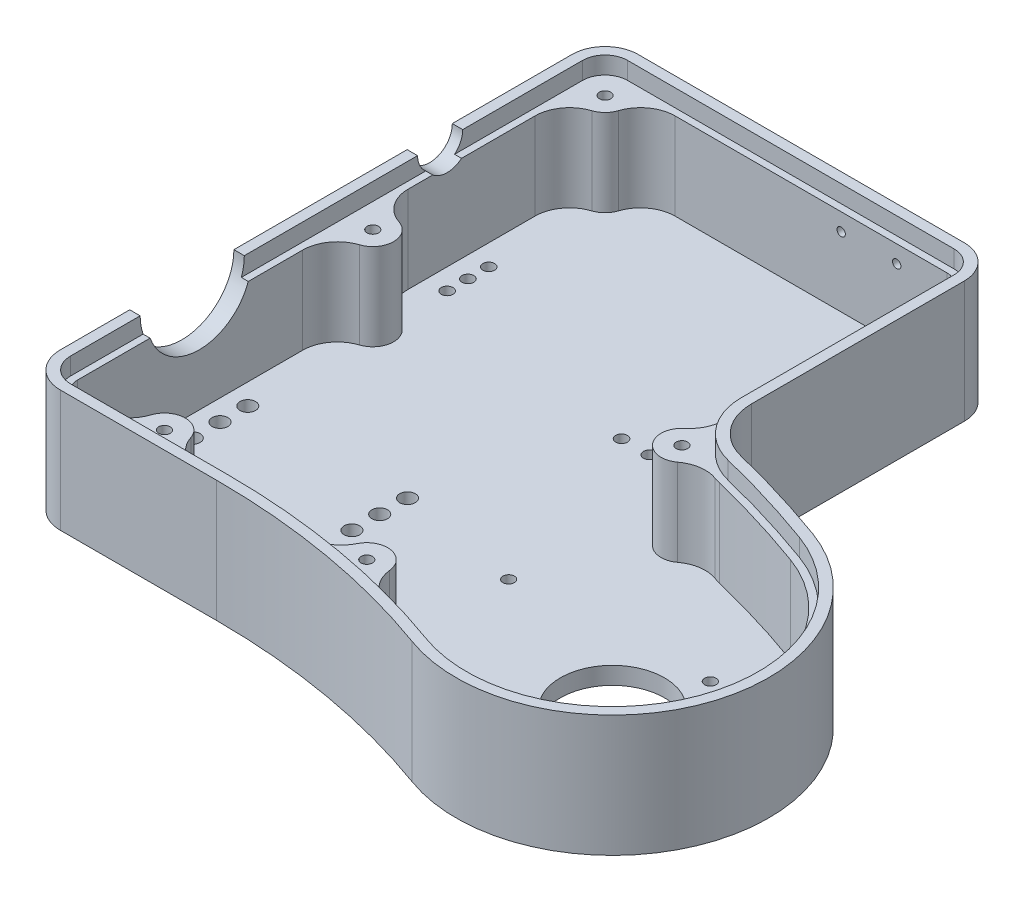
from build123d import *

# Parameters (mm, degrees)
EXTRUDE_1_DEPTH                  = 35
CUT_EXTRUDE_1_DEPTH              = 30
SKETCH_4_R                       = 15
CUT_EXTRUDE_3_DEPTH              = 10
SKETCH_9_R                       = 6.5
CUT_EXTRUDE_6_DEPTH              = 5
CUT_EXTRUDE_8_REACH              = 183.675
SKETCH_12_R                      = 1.2
CUT_EXTRUDE_9_DEPTH              = 5
CUT_EXTRUDE_10_REACH             = 7
SKETCH_14_R                      = 1.7
SKETCH_15_R                      = 1.7
CUT_EXTRUDE_11_DEPTH             = 5
SKETCH_21_R                      = 6
EXTRUDE_7_DEPTH                  = 25
FILLET_1_R                       = 10
FILLET_2_R                       = 10
FILLET_3_R                       = 10
CUT_EXTRUDE_17_REACH             = 7
SKETCH_23_R                      = 2.25
SKETCH_24_R                      = 2.25
CUT_EXTRUDE_18_DEPTH             = 36
HOLE_WIZARD_M4_1_D               = 3.3
HOLE_WIZARD_M4_1_DEPTH           = 11.5
HOLE_WIZARD_M4_1_TIP             = 0.991420021
CUT_EXTRUDE_19_REACH             = 37
SKETCH_3_R                       = 15
CUT_EXTRUDE_19_DIRECTION_2_DEPTH = 1
HOLE_WIZARD_M4_2_D               = 3.3
HOLE_WIZARD_M4_2_DEPTH           = 11.5
HOLE_WIZARD_M4_2_TIP             = 0.991420021


with BuildPart() as part:
    # 스케치1 → 보스-돌출1 (new body)
    with BuildSketch(Plane(origin=(0, 0, 0), x_dir=(1, 0, 0), z_dir=(0, 1, 0))):
        with BuildLine():
            Line((-35.5, 121.9), (10, 121.9))
            Line((10, 121.9), (58.5, 121.9))
            ThreePointArc((58.5, 121.9), (65.217514421, 119.117514421), (68, 112.4))
            Line((68, 112.4), (68, 51.135104302))
            ThreePointArc((68, 51.135104302), (71.192111556, 41.884495106), (79.409836066, 36.571082779))
            ThreePointArc((79.409836066, 36.571082779), (94.419473689, 32.440718825), (109.185841564, 27.510860028))
            ThreePointArc((109.185841564, 27.510860028), (136.08110305, -30.166214357), (78.404028665, -57.061475843))
            ThreePointArc((78.404028665, -57.061475843), (44.729635533, -48.038449398), (10, -45))
            Line((10, -45), (-35, -45))
            ThreePointArc((-35, -45), (-42.071067812, -42.071067812), (-45, -35))
            Line((-45, -35), (-45, 112.4))
            ThreePointArc((-45, 112.4), (-42.217514421, 119.117514421), (-35.5, 121.9))
        make_face()
    extrude(amount=EXTRUDE_1_DEPTH)

    # 스케치2 → 컷-돌출1 (cut)
    with BuildSketch(Plane(origin=(0, 35, 0), x_dir=(1, 0, 0), z_dir=(0, 1, 0))):
        with BuildLine():
            Line((-40, 112.4), (-40, -35))
            ThreePointArc((-40, -35), (-38.535533906, -38.535533906), (-35, -40))
            Line((-35, -40), (10, -40))
            ThreePointArc((10, -40), (45.597876422, -43.114410632), (80.114129382, -52.363012739))
            ThreePointArc((80.114129382, -52.363012739), (131.382639946, -28.45611364), (107.475740848, 22.812396924))
            ThreePointArc((107.475740848, 22.812396924), (92.963965522, 27.657258155), (78.213114754, 31.716408938))
            ThreePointArc((78.213114754, 31.716408938), (67.256148741, 38.800958708), (63, 51.135104302))
            Line((63, 51.135104302), (63, 112.4))
            ThreePointArc((63, 112.4), (61.681980515, 115.581980515), (58.5, 116.9))
            Line((58.5, 116.9), (-35.5, 116.9))
            ThreePointArc((-35.5, 116.9), (-38.681980515, 115.581980515), (-40, 112.4))
        make_face()
    extrude(amount=-CUT_EXTRUDE_1_DEPTH, mode=Mode.SUBTRACT)

    # 스케치4 → 컷-돌출3 (cut)
    with BuildSketch(Plane.ZY.offset(45)):
        with Locations((0, 35)):
            Circle(SKETCH_4_R)
    extrude(amount=-CUT_EXTRUDE_3_DEPTH, mode=Mode.SUBTRACT)

    # 스케치9 → 컷-돌출6 (cut)
    with BuildSketch(Plane.ZY.offset(45)):
        with Locations((-71.4, 35)):
            Circle(SKETCH_9_R)
    extrude(amount=-CUT_EXTRUDE_6_DEPTH, mode=Mode.SUBTRACT)

    # 스케치12 → 컷-돌출8 (cut, up to next)
    with BuildSketch(Plane(origin=(0, 0, -121.9), x_dir=(-1, 0, 0), z_dir=(0, 0, -1)), mode=Mode.PRIVATE) as cut_extrude_8_sk1:
        with Locations((-44, 25)):
            Circle(SKETCH_12_R)
    cut_extrude_8_tool1 = extrude(cut_extrude_8_sk1.sketch, amount=-CUT_EXTRUDE_8_REACH, mode=Mode.PRIVATE) & part.part
    add(cut_extrude_8_tool1.solids().sort_by_distance((44, 25, -121.9))[0], mode=Mode.SUBTRACT)
    # 스케치12 → 컷-돌출8 (cut, up to next)
    with BuildSketch(Plane(origin=(0, 0, -121.9), x_dir=(-1, 0, 0), z_dir=(0, 0, -1)), mode=Mode.PRIVATE) as cut_extrude_8_sk2:
        with Locations((-28, 25)):
            Circle(SKETCH_12_R)
    cut_extrude_8_tool2 = extrude(cut_extrude_8_sk2.sketch, amount=-CUT_EXTRUDE_8_REACH, mode=Mode.PRIVATE) & part.part
    add(cut_extrude_8_tool2.solids().sort_by_distance((28, 25, -121.9))[0], mode=Mode.SUBTRACT)

    # 스케치13 → 컷-돌출9 (cut)
    with BuildSketch(Plane(origin=(0, 35, 0), x_dir=(1, 0, 0), z_dir=(0, 1, 0))):
        with BuildLine():
            Line((-42, -35), (-42, -28.086909805))
            Line((-42, -28.086909805), (-42, 64.9))
            Line((-42, 64.9), (-42, 77.9))
            Line((-42, 77.9), (-42, 112.4))
            ThreePointArc((-42, 112.4), (-40.096194078, 116.996194078), (-35.5, 118.9))
            Line((-35.5, 118.9), (58.5, 118.9))
            ThreePointArc((58.5, 118.9), (63.096194078, 116.996194078), (65, 112.4))
            Line((65, 112.4), (65, 51.135104302))
            ThreePointArc((65, 51.135104302), (68.830533867, 40.034373267), (78.691803279, 33.658278474))
            ThreePointArc((78.691803279, 33.658278474), (93.546168789, 29.570642423), (108.159781134, 24.691782166))
            ThreePointArc((108.159781134, 24.691782166), (133.262025188, -29.140153927), (79.430089095, -54.24239798))
            ThreePointArc((79.430089095, -54.24239798), (45.250580066, -45.084026139), (10, -42))
            Line((10, -42), (-35, -42))
            ThreePointArc((-35, -42), (-39.949747468, -39.949747468), (-42, -35))
        make_face()
        with BuildLine():
            Line((-40, -28.086909805), (-40, -35))
            ThreePointArc((-40, -35), (-38.535533906, -38.535533906), (-35, -40))
            Line((-35, -40), (10, -40))
            ThreePointArc((10, -40), (45.597876422, -43.114410632), (80.114129382, -52.363012739))
            ThreePointArc((80.114129382, -52.363012739), (131.382639946, -28.45611364), (107.475740848, 22.812396924))
            ThreePointArc((107.475740848, 22.812396924), (92.963965522, 27.657258155), (78.213114754, 31.716408938))
            ThreePointArc((78.213114754, 31.716408938), (67.256148741, 38.800958708), (63, 51.135104302))
            Line((63, 51.135104302), (63, 112.4))
            ThreePointArc((63, 112.4), (61.681980515, 115.581980515), (58.5, 116.9))
            Line((58.5, 116.9), (-35.5, 116.9))
            ThreePointArc((-35.5, 116.9), (-38.681980515, 115.581980515), (-40, 112.4))
            Line((-40, 112.4), (-40, 77.9))
            Line((-40, 77.9), (-40, 64.9))
            Line((-40, 64.9), (-40, -28.086909805))
        make_face(mode=Mode.SUBTRACT)
    extrude(amount=-CUT_EXTRUDE_9_DEPTH, mode=Mode.SUBTRACT)

    # 스케치14 → 컷-돌출10 (cut, up to next)
    with BuildSketch(Plane(origin=(0, 5, 0), x_dir=(1, 0, 0), z_dir=(0, 1, 0)), mode=Mode.PRIVATE) as cut_extrude_10_sk1:
        with Locations((36, 53.65)):
            Circle(SKETCH_14_R)
    cut_extrude_10_tool1 = extrude(cut_extrude_10_sk1.sketch, amount=-CUT_EXTRUDE_10_REACH, mode=Mode.PRIVATE) & part.part
    add(cut_extrude_10_tool1.solids().sort_by_distance((36, 5, -53.65))[0], mode=Mode.SUBTRACT)
    # 스케치14 → 컷-돌출10 (cut, up to next)
    with BuildSketch(Plane(origin=(0, 5, 0), x_dir=(1, 0, 0), z_dir=(0, 1, 0)), mode=Mode.PRIVATE) as cut_extrude_10_sk2:
        with Locations((28, 53.65)):
            Circle(SKETCH_14_R)
    cut_extrude_10_tool2 = extrude(cut_extrude_10_sk2.sketch, amount=-CUT_EXTRUDE_10_REACH, mode=Mode.PRIVATE) & part.part
    add(cut_extrude_10_tool2.solids().sort_by_distance((28, 5, -53.65))[0], mode=Mode.SUBTRACT)
    # 스케치14 → 컷-돌출10 (cut, up to next)
    with BuildSketch(Plane(origin=(0, 5, 0), x_dir=(1, 0, 0), z_dir=(0, 1, 0)), mode=Mode.PRIVATE) as cut_extrude_10_sk3:
        with Locations((44, 53.65)):
            Circle(SKETCH_14_R)
    cut_extrude_10_tool3 = extrude(cut_extrude_10_sk3.sketch, amount=-CUT_EXTRUDE_10_REACH, mode=Mode.PRIVATE) & part.part
    add(cut_extrude_10_tool3.solids().sort_by_distance((44, 5, -53.65))[0], mode=Mode.SUBTRACT)

    # 스케치15 → 컷-돌출11 (cut)
    with BuildSketch(Plane.XZ):
        with Locations((-34, -65.4)):
            Circle(SKETCH_15_R)
        with Locations((-34, -71.4)):
            Circle(SKETCH_15_R)
        with Locations((-34, -77.4)):
            Circle(SKETCH_15_R)
    extrude(amount=-CUT_EXTRUDE_11_DEPTH, mode=Mode.SUBTRACT)

    # 스케치21 → 보스-돌출7 (add)
    with BuildSketch(Plane(origin=(0, 5, 0), x_dir=(1, 0, 0), z_dir=(0, 1, 0))):
        with Locations((-35, 111.9)):
            Circle(SKETCH_21_R)
        with Locations((-15, -35)):
            Circle(SKETCH_21_R)
        with Locations((-35, 45)):
            Circle(SKETCH_21_R)
        with Locations((63.320185927, 35.717422309)):
            Circle(SKETCH_21_R)
        with Locations((46.46611731, -38.190371867)):
            Circle(SKETCH_21_R)
    extrude(amount=EXTRUDE_7_DEPTH)

    # 필렛1
    fillet_1_edges = [part.edges().sort_by_distance(p)[0] for p in [
        (-40, 17.5, -108.58337521),
        (-31.68337521, 17.5, -116.9),
        (69.25374262, 17.5, -36.60787442),
        (65.60491959, 17.5, -41.265394199),
        (42.366311792, 17.5, 42.571193105),
        (48.820345194, 17.5, 43.709213328),
    ]]
    fillet(fillet_1_edges, radius=FILLET_1_R)

    # 필렛2
    fillet_2_edges = [part.edges().sort_by_distance(p)[0] for p in [
        (-40, 17.5, -48.31662479),
        (-40, 17.5, -41.68337521),
    ]]
    fillet(fillet_2_edges, radius=FILLET_2_R)

    # 필렛3
    fillet_3_edges = [part.edges().sort_by_distance(p)[0] for p in [
        (-18.31662479, 17.5, 40),
        (-11.68337521, 17.5, 40),
    ]]
    fillet(fillet_3_edges, radius=FILLET_3_R)

    # 스케치23 → 컷-돌출17 (cut, up to next)
    with BuildSketch(Plane(origin=(0, 5, 0), x_dir=(1, 0, 0), z_dir=(0, 1, 0)), mode=Mode.PRIVATE) as cut_extrude_17_sk1:
        with Locations((12, 0)):
            Circle(SKETCH_23_R)
    cut_extrude_17_tool1 = extrude(cut_extrude_17_sk1.sketch, amount=-CUT_EXTRUDE_17_REACH, mode=Mode.PRIVATE) & part.part
    add(cut_extrude_17_tool1.solids().sort_by_distance((12, 5, 0))[0], mode=Mode.SUBTRACT)
    # 스케치23 → 컷-돌출17 (cut, up to next)
    with BuildSketch(Plane(origin=(0, 5, 0), x_dir=(1, 0, 0), z_dir=(0, 1, 0)), mode=Mode.PRIVATE) as cut_extrude_17_sk2:
        with Locations((12, -8)):
            Circle(SKETCH_23_R)
    cut_extrude_17_tool2 = extrude(cut_extrude_17_sk2.sketch, amount=-CUT_EXTRUDE_17_REACH, mode=Mode.PRIVATE) & part.part
    add(cut_extrude_17_tool2.solids().sort_by_distance((12, 5, 8))[0], mode=Mode.SUBTRACT)
    # 스케치23 → 컷-돌출17 (cut, up to next)
    with BuildSketch(Plane(origin=(0, 5, 0), x_dir=(1, 0, 0), z_dir=(0, 1, 0)), mode=Mode.PRIVATE) as cut_extrude_17_sk3:
        with Locations((12, 8)):
            Circle(SKETCH_23_R)
    cut_extrude_17_tool3 = extrude(cut_extrude_17_sk3.sketch, amount=-CUT_EXTRUDE_17_REACH, mode=Mode.PRIVATE) & part.part
    add(cut_extrude_17_tool3.solids().sort_by_distance((12, 5, -8))[0], mode=Mode.SUBTRACT)

    # 스케치24 → 컷-돌출18 (cut, through all)
    with BuildSketch(Plane.XZ):
        with Locations((-34, -8)):
            Circle(SKETCH_24_R)
        with Locations((-34, 0)):
            Circle(SKETCH_24_R)
        with Locations((-34, 8)):
            Circle(SKETCH_24_R)
    extrude(amount=-CUT_EXTRUDE_18_DEPTH, mode=Mode.SUBTRACT)

    # M4 나사 구멍1
    with Locations(Plane(origin=(0, 30, 0), x_dir=(1, 0, 0), z_dir=(0, 1, 0))):
        with Locations((-35, 111.9), (-35, 45), (-15, -35), (46.46611731, -38.190371867), (63.320185927, 35.717422309)):
            Hole(HOLE_WIZARD_M4_1_D / 2, depth=HOLE_WIZARD_M4_1_DEPTH)
            with Locations((0, 0, -(HOLE_WIZARD_M4_1_DEPTH + HOLE_WIZARD_M4_1_TIP / 2))):  # 118° drill point
                Cone(0, HOLE_WIZARD_M4_1_D / 2, HOLE_WIZARD_M4_1_TIP, mode=Mode.SUBTRACT)

    # 스케치3 → 컷-돌출19 (cut, up to next)
    with BuildSketch(Plane.XZ, mode=Mode.PRIVATE) as cut_extrude_19_sk1:
        with Locations((93.794935115, 14.775307907)):
            Circle(SKETCH_3_R)
    cut_extrude_19_tool1 = extrude(cut_extrude_19_sk1.sketch, amount=-CUT_EXTRUDE_19_REACH, mode=Mode.PRIVATE) & part.part
    add(cut_extrude_19_tool1.solids().sort_by_distance((93.794935, 0, 14.775308))[0], mode=Mode.SUBTRACT)

    # 스케치3 → 컷-돌출19 direction 2 (cut)
    with BuildSketch(Plane.XZ):
        with Locations((93.794935115, 14.775307907)):
            Circle(SKETCH_3_R)
    extrude(amount=CUT_EXTRUDE_19_DIRECTION_2_DEPTH, mode=Mode.SUBTRACT)

    # M4 나사 구멍2
    with Locations(Plane(origin=(0, 5, 0), x_dir=(1, 0, 0), z_dir=(0, 1, 0))):
        with Locations((46.810304075, 2.325699259), (101.319378268, 5.89792975), (112.588787531, -21.615710774), (86.270491962, -35.448545565)):
            Hole(HOLE_WIZARD_M4_2_D / 2, depth=HOLE_WIZARD_M4_2_DEPTH)
            with Locations((0, 0, -(HOLE_WIZARD_M4_2_DEPTH + HOLE_WIZARD_M4_2_TIP / 2))):  # 118° drill point
                Cone(0, HOLE_WIZARD_M4_2_D / 2, HOLE_WIZARD_M4_2_TIP, mode=Mode.SUBTRACT)


solid = part.part
